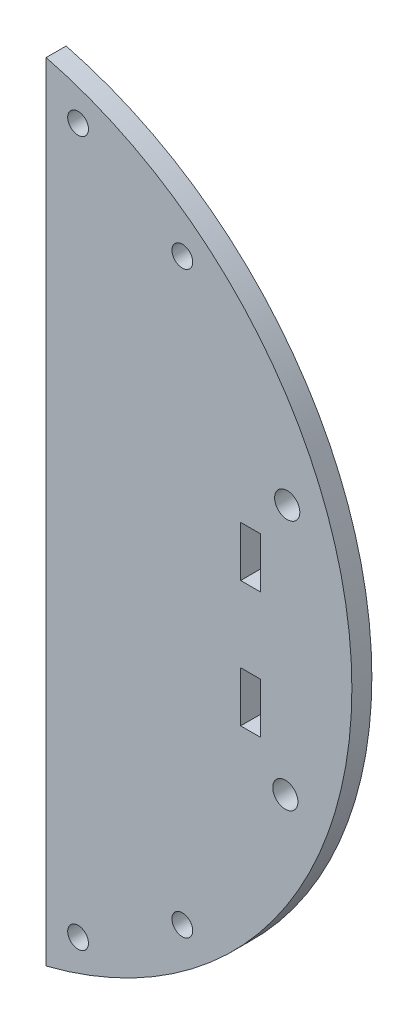
from build123d import *

# Parameters (mm, degrees)
SKETCH1_R           = 1.65
SKETCH1_R_2         = 2
BOSS_EXTRUDE1_DEPTH = 3.175
SKETCH2_W           = 3.175
SKETCH2_H           = 8
CUT_EXTRUDE1_DEPTH  = 4.175


with BuildPart() as part:
    # Sketch1 → Boss-Extrude1 (new body)
    with BuildSketch(Plane(origin=(0, 0, 0), x_dir=(-1, 0, 0), z_dir=(0, 0, 1))):
        with BuildLine():
            Line((0, -62.136729163), (0, 62.869580678))
            ThreePointArc((0, 62.869580678), (-48.575, 0.366425758), (0, -62.136729163))
        make_face()
        with Locations((-5.075, 56.366425758)):
            Circle(SKETCH1_R, mode=Mode.SUBTRACT)
        with Locations((-21.638471196, 46.366425758)):
            Circle(SKETCH1_R, mode=Mode.SUBTRACT)
        with Locations((-5.075, -55.633574242)):
            Circle(SKETCH1_R, mode=Mode.SUBTRACT)
        with Locations((-21.638471196, -45.633574242)):
            Circle(SKETCH1_R, mode=Mode.SUBTRACT)
        with Locations((-38, 20.287222228)):
            Circle(SKETCH1_R_2, mode=Mode.SUBTRACT)
        with Locations((-38.301731617, -19.711639731)):
            Circle(SKETCH1_R_2, mode=Mode.SUBTRACT)
    extrude(amount=BOSS_EXTRUDE1_DEPTH)

    # Sketch2 → Cut-Extrude1 (cut, through all)
    with BuildSketch(Plane.XY.offset(3.175)):
        with Locations((32.4875, 9.633574242)):
            Rectangle(SKETCH2_W, SKETCH2_H)
        with Locations((32.4875, -10.366425758)):
            Rectangle(SKETCH2_W, SKETCH2_H)
    extrude(amount=-CUT_EXTRUDE1_DEPTH, mode=Mode.SUBTRACT)


solid = part.part
